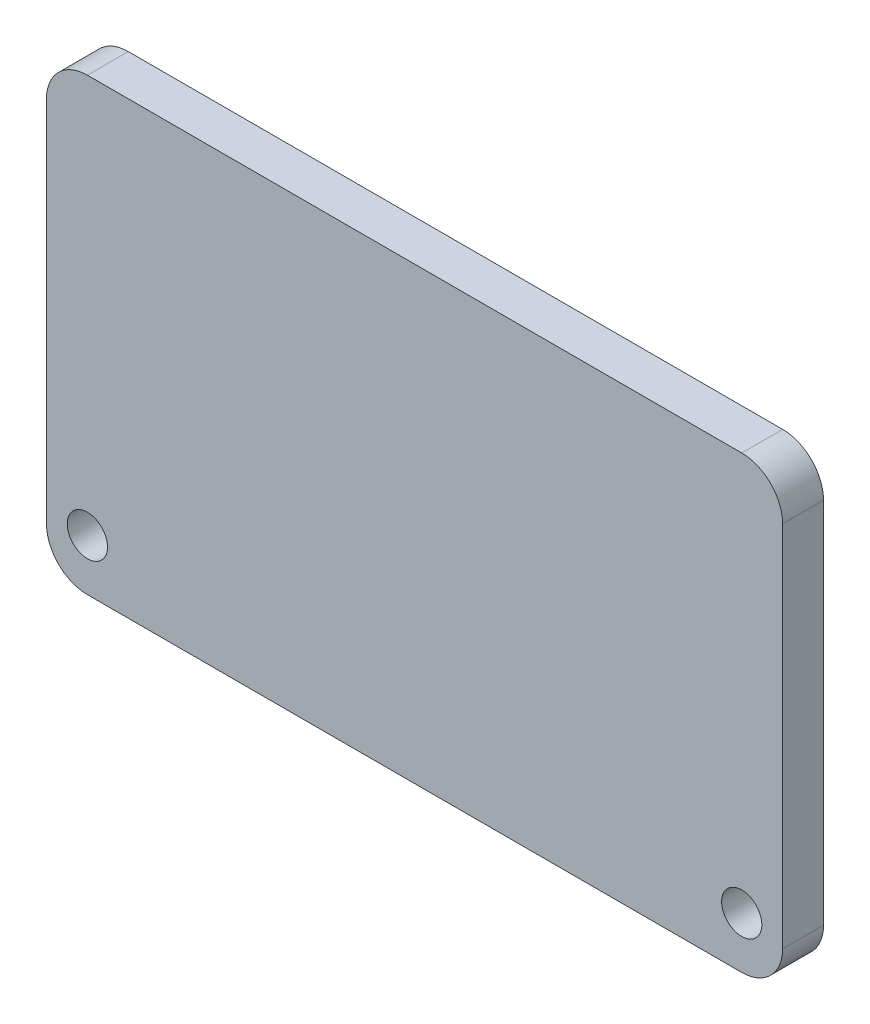
from build123d import *

# Parameters (mm, degrees)
SKETCH1_W           = 45.72
SKETCH1_H           = 27.94
BOSS_EXTRUDE1_DEPTH = 1.27
FILLET1_R           = 2.54
SKETCH2_R           = 1.25
CUT_EXTRUDE1_DEPTH  = 2.54


with BuildPart() as part:
    # Sketch1 → Boss-Extrude1 (new body, symmetric)
    with BuildSketch(Plane.XY):
        Rectangle(SKETCH1_W, SKETCH1_H)
    extrude(amount=BOSS_EXTRUDE1_DEPTH, both=True)

    # Fillet1
    fillet1_edges = [part.edges().sort_by_distance(p)[0] for p in [
        (22.86, -13.97, 0),
        (-22.86, -13.97, 0),
        (-22.86, 13.97, 0),
        (22.86, 13.97, 0),
    ]]
    fillet(fillet1_edges, radius=FILLET1_R)

    # Sketch2 → Cut-Extrude1 (cut)
    with BuildSketch(Plane.XY.offset(1.27)):
        with Locations((-20.32, -10.785792079)):
            Circle(SKETCH2_R)
        with Locations((20.32, -10.785792079)):
            Circle(SKETCH2_R)
    extrude(amount=-CUT_EXTRUDE1_DEPTH, mode=Mode.SUBTRACT)


solid = part.part
